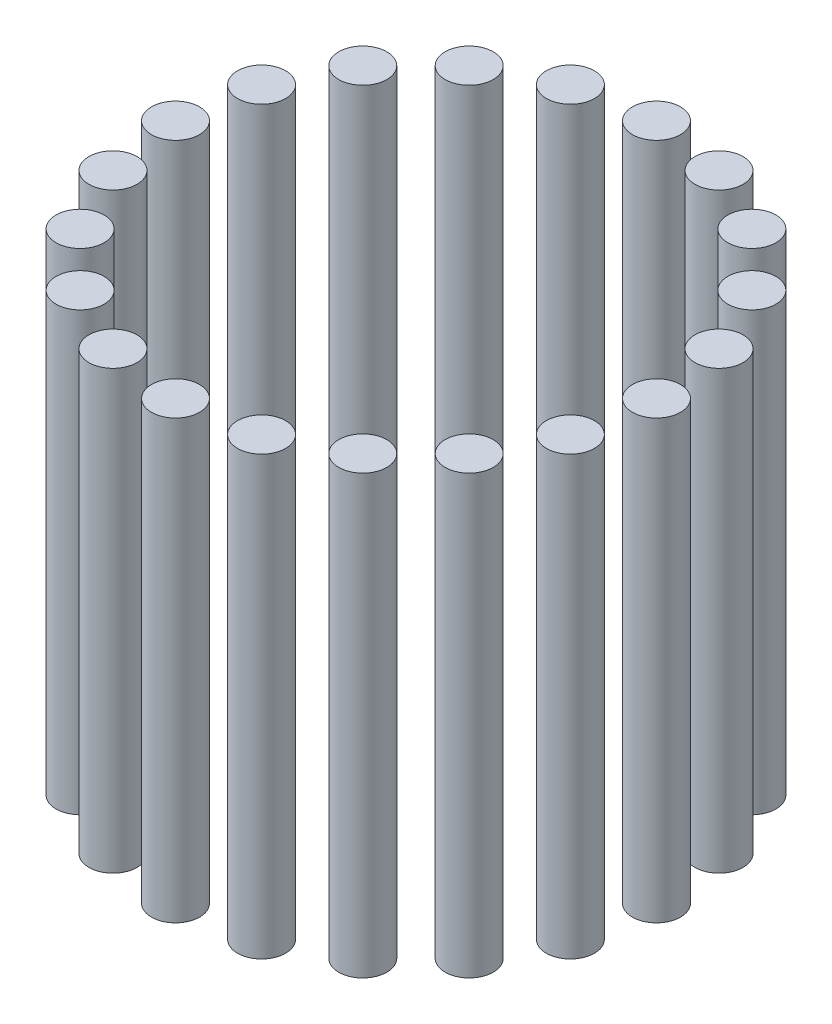
from build123d import *

# Parameters (mm, degrees)
SKETCH1_R              = 5.5
BOSS_EXTRUDE1_DEPTH    = 100
BOSS_EXTRUDE1_2_DEPTH  = 100
BOSS_EXTRUDE1_3_DEPTH  = 100
BOSS_EXTRUDE1_4_DEPTH  = 100
BOSS_EXTRUDE1_5_DEPTH  = 100
BOSS_EXTRUDE1_6_DEPTH  = 100
BOSS_EXTRUDE1_7_DEPTH  = 100
BOSS_EXTRUDE1_8_DEPTH  = 100
BOSS_EXTRUDE1_9_DEPTH  = 100
BOSS_EXTRUDE1_10_DEPTH = 100
BOSS_EXTRUDE1_11_DEPTH = 100
BOSS_EXTRUDE1_12_DEPTH = 100
BOSS_EXTRUDE1_13_DEPTH = 100
BOSS_EXTRUDE1_14_DEPTH = 100
BOSS_EXTRUDE1_15_DEPTH = 100
BOSS_EXTRUDE1_16_DEPTH = 100
BOSS_EXTRUDE1_17_DEPTH = 100
BOSS_EXTRUDE1_18_DEPTH = 100
BOSS_EXTRUDE1_19_DEPTH = 100
BOSS_EXTRUDE1_20_DEPTH = 100


with BuildPart() as part:
    # Sketch1 → Boss-Extrude1 (new body)
    with BuildSketch(Plane(origin=(0, 0, 0), x_dir=(1, 0, 0), z_dir=(0, 1, 0))):
        with Locations((55, 0)):
            Circle(SKETCH1_R)
    extrude(amount=BOSS_EXTRUDE1_DEPTH)


with BuildPart() as body_2:
    # Sketch1 → Boss-Extrude1 2 (new body)
    with BuildSketch(Plane(origin=(0, 0, 0), x_dir=(1, 0, 0), z_dir=(0, 1, 0))):
        with Locations((52.308108396, -16.995934691)):
            Circle(SKETCH1_R)
    extrude(amount=BOSS_EXTRUDE1_2_DEPTH)


with BuildPart() as body_3:
    # Sketch1 → Boss-Extrude1 3 (new body)
    with BuildSketch(Plane(origin=(0, 0, 0), x_dir=(1, 0, 0), z_dir=(0, 1, 0))):
        with Locations((44.495934691, -32.328188876)):
            Circle(SKETCH1_R)
    extrude(amount=BOSS_EXTRUDE1_3_DEPTH)


with BuildPart() as body_4:
    # Sketch1 → Boss-Extrude1 4 (new body)
    with BuildSketch(Plane(origin=(0, 0, 0), x_dir=(1, 0, 0), z_dir=(0, 1, 0))):
        with Locations((32.328188876, -44.495934691)):
            Circle(SKETCH1_R)
    extrude(amount=BOSS_EXTRUDE1_4_DEPTH)


with BuildPart() as body_5:
    # Sketch1 → Boss-Extrude1 5 (new body)
    with BuildSketch(Plane(origin=(0, 0, 0), x_dir=(1, 0, 0), z_dir=(0, 1, 0))):
        with Locations((16.995934691, -52.308108396)):
            Circle(SKETCH1_R)
    extrude(amount=BOSS_EXTRUDE1_5_DEPTH)


with BuildPart() as body_6:
    # Sketch1 → Boss-Extrude1 6 (new body)
    with BuildSketch(Plane(origin=(0, 0, 0), x_dir=(1, 0, 0), z_dir=(0, 1, 0))):
        with Locations((0, -55)):
            Circle(SKETCH1_R)
    extrude(amount=BOSS_EXTRUDE1_6_DEPTH)


with BuildPart() as body_7:
    # Sketch1 → Boss-Extrude1 7 (new body)
    with BuildSketch(Plane(origin=(0, 0, 0), x_dir=(1, 0, 0), z_dir=(0, 1, 0))):
        with Locations((-16.995934691, -52.308108396)):
            Circle(SKETCH1_R)
    extrude(amount=BOSS_EXTRUDE1_7_DEPTH)


with BuildPart() as body_8:
    # Sketch1 → Boss-Extrude1 8 (new body)
    with BuildSketch(Plane(origin=(0, 0, 0), x_dir=(1, 0, 0), z_dir=(0, 1, 0))):
        with Locations((-32.328188876, -44.495934691)):
            Circle(SKETCH1_R)
    extrude(amount=BOSS_EXTRUDE1_8_DEPTH)


with BuildPart() as body_9:
    # Sketch1 → Boss-Extrude1 9 (new body)
    with BuildSketch(Plane(origin=(0, 0, 0), x_dir=(1, 0, 0), z_dir=(0, 1, 0))):
        with Locations((-44.495934691, -32.328188876)):
            Circle(SKETCH1_R)
    extrude(amount=BOSS_EXTRUDE1_9_DEPTH)


with BuildPart() as body_10:
    # Sketch1 → Boss-Extrude1 10 (new body)
    with BuildSketch(Plane(origin=(0, 0, 0), x_dir=(1, 0, 0), z_dir=(0, 1, 0))):
        with Locations((-52.308108396, -16.995934691)):
            Circle(SKETCH1_R)
    extrude(amount=BOSS_EXTRUDE1_10_DEPTH)


with BuildPart() as body_11:
    # Sketch1 → Boss-Extrude1 11 (new body)
    with BuildSketch(Plane(origin=(0, 0, 0), x_dir=(1, 0, 0), z_dir=(0, 1, 0))):
        with Locations((-55, 0)):
            Circle(SKETCH1_R)
    extrude(amount=BOSS_EXTRUDE1_11_DEPTH)


with BuildPart() as body_12:
    # Sketch1 → Boss-Extrude1 12 (new body)
    with BuildSketch(Plane(origin=(0, 0, 0), x_dir=(1, 0, 0), z_dir=(0, 1, 0))):
        with Locations((-52.308108396, 16.995934691)):
            Circle(SKETCH1_R)
    extrude(amount=BOSS_EXTRUDE1_12_DEPTH)


with BuildPart() as body_13:
    # Sketch1 → Boss-Extrude1 13 (new body)
    with BuildSketch(Plane(origin=(0, 0, 0), x_dir=(1, 0, 0), z_dir=(0, 1, 0))):
        with Locations((-44.495934691, 32.328188876)):
            Circle(SKETCH1_R)
    extrude(amount=BOSS_EXTRUDE1_13_DEPTH)


with BuildPart() as body_14:
    # Sketch1 → Boss-Extrude1 14 (new body)
    with BuildSketch(Plane(origin=(0, 0, 0), x_dir=(1, 0, 0), z_dir=(0, 1, 0))):
        with Locations((-32.328188876, 44.495934691)):
            Circle(SKETCH1_R)
    extrude(amount=BOSS_EXTRUDE1_14_DEPTH)


with BuildPart() as body_15:
    # Sketch1 → Boss-Extrude1 15 (new body)
    with BuildSketch(Plane(origin=(0, 0, 0), x_dir=(1, 0, 0), z_dir=(0, 1, 0))):
        with Locations((-16.995934691, 52.308108396)):
            Circle(SKETCH1_R)
    extrude(amount=BOSS_EXTRUDE1_15_DEPTH)


with BuildPart() as body_16:
    # Sketch1 → Boss-Extrude1 16 (new body)
    with BuildSketch(Plane(origin=(0, 0, 0), x_dir=(1, 0, 0), z_dir=(0, 1, 0))):
        with Locations((0, 55)):
            Circle(SKETCH1_R)
    extrude(amount=BOSS_EXTRUDE1_16_DEPTH)


with BuildPart() as body_17:
    # Sketch1 → Boss-Extrude1 17 (new body)
    with BuildSketch(Plane(origin=(0, 0, 0), x_dir=(1, 0, 0), z_dir=(0, 1, 0))):
        with Locations((16.995934691, 52.308108396)):
            Circle(SKETCH1_R)
    extrude(amount=BOSS_EXTRUDE1_17_DEPTH)


with BuildPart() as body_18:
    # Sketch1 → Boss-Extrude1 18 (new body)
    with BuildSketch(Plane(origin=(0, 0, 0), x_dir=(1, 0, 0), z_dir=(0, 1, 0))):
        with Locations((32.328188876, 44.495934691)):
            Circle(SKETCH1_R)
    extrude(amount=BOSS_EXTRUDE1_18_DEPTH)


with BuildPart() as body_19:
    # Sketch1 → Boss-Extrude1 19 (new body)
    with BuildSketch(Plane(origin=(0, 0, 0), x_dir=(1, 0, 0), z_dir=(0, 1, 0))):
        with Locations((44.495934691, 32.328188876)):
            Circle(SKETCH1_R)
    extrude(amount=BOSS_EXTRUDE1_19_DEPTH)


with BuildPart() as body_20:
    # Sketch1 → Boss-Extrude1 20 (new body)
    with BuildSketch(Plane(origin=(0, 0, 0), x_dir=(1, 0, 0), z_dir=(0, 1, 0))):
        with Locations((52.308108396, 16.995934691)):
            Circle(SKETCH1_R)
    extrude(amount=BOSS_EXTRUDE1_20_DEPTH)


solid = Compound([part.part, body_2.part, body_3.part, body_4.part, body_5.part, body_6.part, body_7.part, body_8.part, body_9.part, body_10.part, body_11.part, body_12.part, body_13.part, body_14.part, body_15.part, body_16.part, body_17.part, body_18.part, body_19.part, body_20.part])
